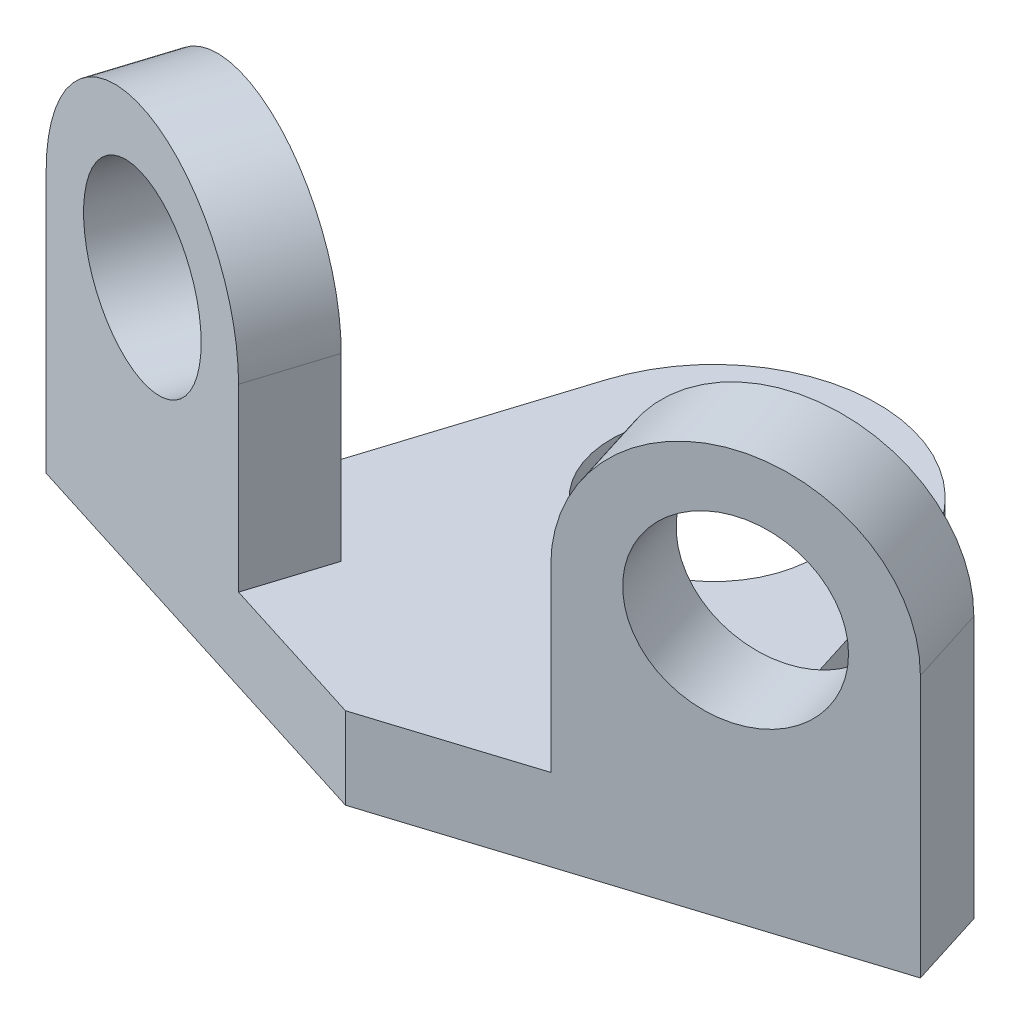
from build123d import *

# Parameters (mm, degrees)
SKETCH1_R           = 12.5
BOSS_EXTRUDE1_DEPTH = 10
SKETCH2_R           = 11
BOSS_EXTRUDE2_DEPTH = 10
SKETCH4_R           = 11
BOSS_EXTRUDE3_DEPTH = 10


with BuildPart() as part:
    # Sketch1 → Boss-Extrude1 (new body)
    with BuildSketch(Plane(origin=(0, 0, 0), x_dir=(1, 0, 0), z_dir=(0, 1, 0))):
        with BuildLine():
            Line((0, 0), (53.408149242, 16.839524772))
            Line((53.408149242, 16.839524772), (50.401091247, 26.37669428))
            Line((50.401091247, 26.37669428), (28.972750838, 19.620364501))
            Line((28.972750838, 19.620364501), (19.074339015, 51.01411599))
            ThreePointArc((19.074339015, 51.01411599), (0, 65), (-19.074339015, 51.01411599))
            Line((-19.074339015, 51.01411599), (-28.972750838, 19.620364501))
            Line((-28.972750838, 19.620364501), (-50.401091247, 26.37669428))
            Line((-50.401091247, 26.37669428), (-53.408149242, 16.839524772))
            Line((-53.408149242, 16.839524772), (0, 0))
        make_face()
        with Locations((0, 45)):
            Circle(SKETCH1_R, mode=Mode.SUBTRACT)
    extrude(amount=BOSS_EXTRUDE1_DEPTH)

    # Sketch2 → Boss-Extrude2 (add)
    with BuildSketch(Plane(origin=(0, 0, 0), x_dir=(0.953716951, 0, -0.3007058), z_dir=(0.3007058, 0, 0.953716951))):
        with BuildLine():
            Line((56, 32), (56, 10))
            Line((56, 10), (20, 10))
            Line((20, 10), (20, 32))
            ThreePointArc((20, 32), (38, 50), (56, 32))
        make_face()
        with Locations((38, 32)):
            Circle(SKETCH2_R, mode=Mode.SUBTRACT)
    extrude(amount=-BOSS_EXTRUDE2_DEPTH)

    # Sketch4 → Boss-Extrude3 (add)
    with BuildSketch(Plane(origin=(0, 0, 0), x_dir=(0.953716951, 0, 0.3007058), z_dir=(-0.3007058, 0, 0.953716951))):
        with BuildLine():
            Line((-20, 10), (-20, 32))
            ThreePointArc((-20, 32), (-38, 50), (-56, 32))
            Line((-56, 32), (-56, 10))
            Line((-56, 10), (-20, 10))
        make_face()
        with Locations((-38, 32)):
            Circle(SKETCH4_R, mode=Mode.SUBTRACT)
    extrude(amount=-BOSS_EXTRUDE3_DEPTH)


solid = part.part
